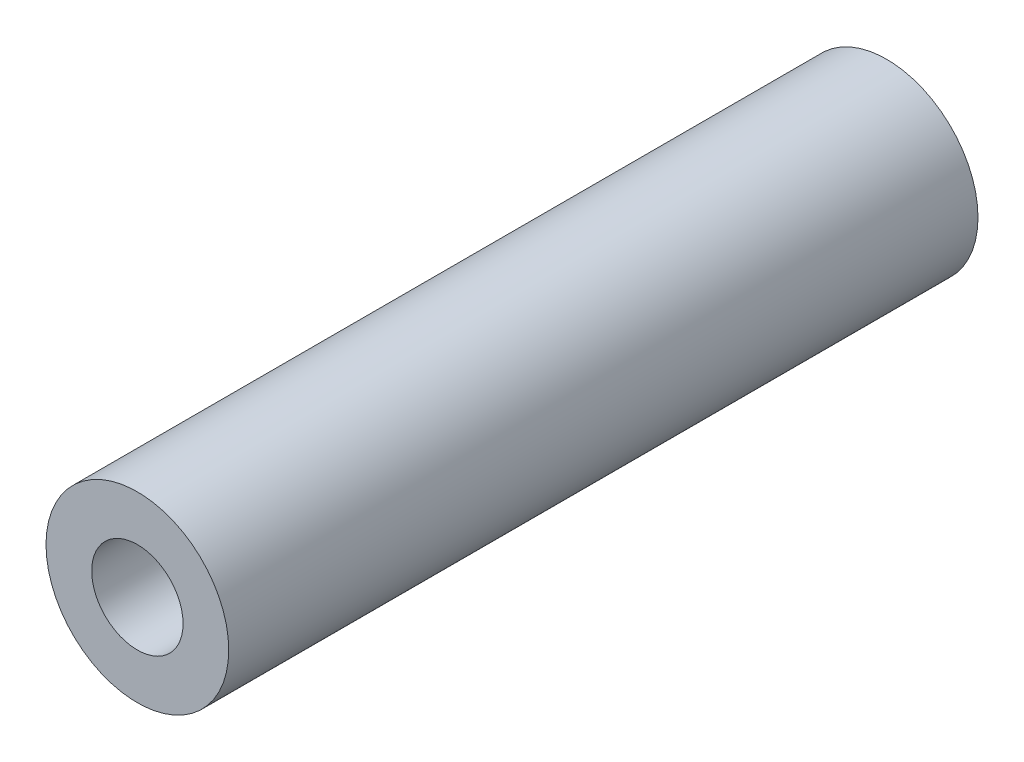
from build123d import *

# Parameters (mm, degrees)
SKETCH1_R           = 6.35
SKETCH1_R_2         = 3.175
BOSS_EXTRUDE1_DEPTH = 52.07


with BuildPart() as part:
    # Sketch1 → Boss-Extrude1 (new body)
    with BuildSketch(Plane.XY):
        Circle(SKETCH1_R)
        Circle(SKETCH1_R_2, mode=Mode.SUBTRACT)
    extrude(amount=BOSS_EXTRUDE1_DEPTH)


solid = part.part
